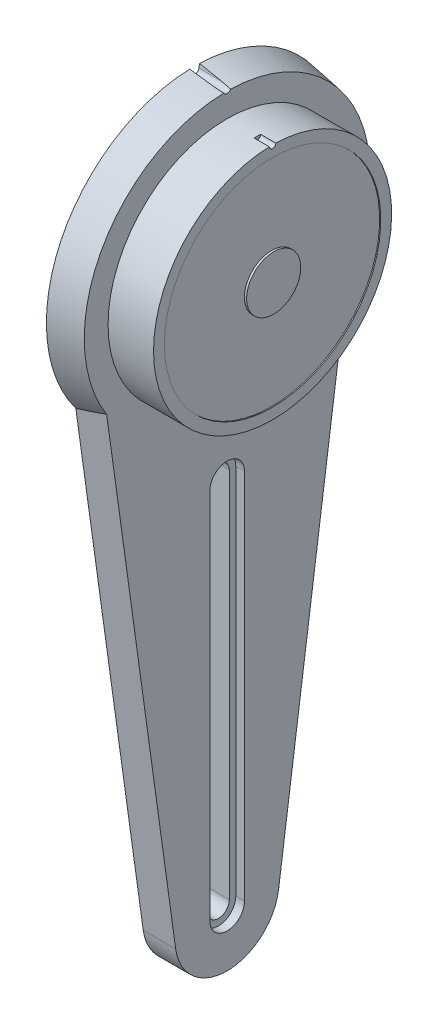
from build123d import *

# Parameters (mm, degrees)
ESQUISSE2_R                        = 0.75
ENL_V_MAT_EXTRU_1_DEPTH            = 3.5
ENL_V_MAT_EXTRU_2_DEPTH            = 50.615395796
EXTRUSION1_DEPTH                   = 7.5
ENL_V_MAT_EXTRU_3_DEPTH            = 3.5
ENL_V_MAT_EXTRU_3_DRAFT            = -7
ENL_V_MAT_EXTRU_3_PROFILE_2_DEPTH  = 3.5
ENL_V_MAT_EXTRU_3_PROFILE_2_DRAFT  = -7
ENL_V_MAT_EXTRU_3_PROFILE_3_DEPTH  = 3.5
ENL_V_MAT_EXTRU_3_PROFILE_3_DRAFT  = -7
ENL_V_MAT_EXTRU_3_PROFILE_4_DEPTH  = 3.5
ENL_V_MAT_EXTRU_3_PROFILE_4_DRAFT  = -7
ENL_V_MAT_EXTRU_3_PROFILE_5_DEPTH  = 3.5
ENL_V_MAT_EXTRU_3_PROFILE_5_DRAFT  = -7
ENL_V_MAT_EXTRU_3_PROFILE_6_DEPTH  = 3.5
ENL_V_MAT_EXTRU_3_PROFILE_6_DRAFT  = -7
ENL_V_MAT_EXTRU_3_PROFILE_7_DEPTH  = 3.5
ENL_V_MAT_EXTRU_3_PROFILE_7_DRAFT  = -7
ENL_V_MAT_EXTRU_3_PROFILE_8_DEPTH  = 3.5
ENL_V_MAT_EXTRU_3_PROFILE_8_DRAFT  = -7
ENL_V_MAT_EXTRU_3_PROFILE_9_DEPTH  = 3.5
ENL_V_MAT_EXTRU_3_PROFILE_9_DRAFT  = -7
ENL_V_MAT_EXTRU_3_PROFILE_10_DEPTH = 3.5
ENL_V_MAT_EXTRU_3_PROFILE_10_DRAFT = -7
ENL_V_MAT_EXTRU_4_DEPTH            = 2


with BuildPart() as part:
    # Esquisse1 → Révolution1 (revolve)
    with BuildSketch(Plane.XY, mode=Mode.PRIVATE) as r_volution1_sk:
        Polygon((0, 0), (0, 34.25), (7.5, 33), (7.5, 27.5), (18, 27.5), (18, 25), (17.75, 25), (17.75, 6.25), (18.25, 6.25), (18.25, 0), align=None)
    revolve(r_volution1_sk.sketch.rotate(Axis((-40.966877637, 0, 0), (1, 0, 0)), 90), axis=Axis((-40.966877637, 0, 0), (1, 0, 0)))

    # Esquisse2 → Enlèv. mat.-Extru.1 (cut)
    with BuildSketch(Plane(origin=(18, 0, 0), x_dir=(0, 0, -1), z_dir=(1, 0, 0))):
        with Locations((0, 27.5)):
            Circle(ESQUISSE2_R)
    extrude(amount=-ENL_V_MAT_EXTRU_1_DEPTH, mode=Mode.SUBTRACT)

    # Esquisse3 → Enlèv. mat.-Extru.2 (cut, through all)
    with BuildSketch(Plane(origin=(7.5, 0, 0), x_dir=(0, 0, -1), z_dir=(1, 0, 0))):
        with BuildLine():
            Line((-0.983364169, 33.368354985), (-1.997654411, 38.859376491))
            Line((-1.997654411, 38.859376491), (1.964936251, 38.859376491))
            Line((1.964936251, 38.859376491), (0.984396051, 33.374032918))
            ThreePointArc((0.984396051, 33.374032918), (0.002885468, 32.550004163), (-0.983364169, 33.368354985))
        make_face()
    extrude(amount=-ENL_V_MAT_EXTRU_2_DEPTH, mode=Mode.SUBTRACT)

    # Esquisse4 → Extrusion1 (add)
    with BuildSketch(Plane.ZY):
        with BuildLine():
            Line((29.715450244, -4.122137405), (11.886180098, -132.648854962))
            ThreePointArc((11.886180098, -132.648854962), (0, -143), (-11.886180098, -132.648854962))
            Line((-11.886180098, -132.648854962), (-29.715450244, -4.122137405))
            ThreePointArc((-29.715450244, -4.122137405), (0, 30), (29.715450244, -4.122137405))
        make_face()
        with BuildLine():
            Line((2.5, -45), (2.5, -131))
            ThreePointArc((2.5, -131), (0, -133.5), (-2.5, -131))
            Line((-2.5, -131), (-2.5, -45))
            ThreePointArc((-2.5, -45), (0, -42.5), (2.5, -45))
        make_face(mode=Mode.SUBTRACT)
    extrude(amount=-EXTRUSION1_DEPTH)


with BuildPart() as enl_v_mat_extru_3_tool:
    # Esquisse5 → Enlèv. mat.-Extru.3 (with draft: the straight prism first)
    with BuildSketch(Plane.ZY):
        Polygon((-11.039827175, -106), (-6, -106), (-6, -88), (-13.536793321, -88), align=None)
    extrude(amount=-ENL_V_MAT_EXTRU_3_DEPTH)
    # Enlèv. mat.-Extru.3: the draft: its side faces are tilted about the plane it starts from
    enl_v_mat_extru_3_sides = [enl_v_mat_extru_3_tool.faces().sort_by_distance(p)[0] for p in [
        (1.75, -106, -8.519913587),
        (1.75, -97, -6),
        (1.75, -88, -9.768396661),
        (1.75, -97, -12.288310248),
    ]]
    draft(enl_v_mat_extru_3_sides, Plane.ZY, ENL_V_MAT_EXTRU_3_DRAFT)


with BuildPart() as part_1:
    add(part.part)

    # Enlèv. mat.-Extru.3: cut by enl_v_mat_extru_3_tool
    add(enl_v_mat_extru_3_tool.part, mode=Mode.SUBTRACT)


with BuildPart() as enl_v_mat_extru_3_profile_2_tool:
    # Esquisse5 → Enlèv. mat.-Extru.3 profile 2 (with draft: the straight prism first)
    with BuildSketch(Plane.ZY):
        with BuildLine():
            ThreePointArc((-6, -45), (-4.582575695, -41.127016654), (-1, -39.083920217))
            Line((-1, -39.083920217), (-1, -34.235398347))
            ThreePointArc((-1, -34.235398347), (-6.197147295, -33.684682949), (-11.25, -32.349652239))
            Line((-11.25, -32.349652239), (-11.25, -65))
            Line((-11.25, -65), (-6, -65))
            Line((-6, -65), (-6, -45))
        make_face()
    extrude(amount=-ENL_V_MAT_EXTRU_3_PROFILE_2_DEPTH)
    # Enlèv. mat.-Extru.3 profile 2: the draft: its side faces are tilted about the plane it starts from
    enl_v_mat_extru_3_profile_2_sides = [enl_v_mat_extru_3_profile_2_tool.faces().sort_by_distance(p)[0] for p in [
        (1.75, -41.127016654, -4.582575695),
        (1.75, -36.659659282, -1),
        (1.75, -33.684682949, -6.197147295),
        (1.75, -48.67482612, -11.25),
        (1.75, -65, -8.625),
        (1.75, -55, -6),
    ]]
    draft(enl_v_mat_extru_3_profile_2_sides, Plane.ZY, ENL_V_MAT_EXTRU_3_PROFILE_2_DRAFT)


with BuildPart() as part_2:
    add(part_1.part)

    # Enlèv. mat.-Extru.3 profile 2: cut by enl_v_mat_extru_3_profile_2_tool
    add(enl_v_mat_extru_3_profile_2_tool.part, mode=Mode.SUBTRACT)


with BuildPart() as enl_v_mat_extru_3_profile_3_tool:
    # Esquisse5 → Enlèv. mat.-Extru.3 profile 3 (with draft: the straight prism first)
    with BuildSketch(Plane.ZY):
        with BuildLine():
            Line((-22.116364137, -26.152035052), (-16.727361175, -65))
            Line((-16.727361175, -65), (-13.25, -65))
            Line((-13.25, -65), (-13.25, -31.583223395))
            ThreePointArc((-13.25, -31.583223395), (-17.890482939, -29.206045953), (-22.116364137, -26.152035052))
        make_face()
    extrude(amount=-ENL_V_MAT_EXTRU_3_PROFILE_3_DEPTH)
    # Enlèv. mat.-Extru.3 profile 3: the draft: its side faces are tilted about the plane it starts from
    enl_v_mat_extru_3_profile_3_sides = [enl_v_mat_extru_3_profile_3_tool.faces().sort_by_distance(p)[0] for p in [
        (1.75, -45.576017526, -19.421862656),
        (1.75, -65, -14.988680587),
        (1.75, -48.291611697, -13.25),
        (1.75, -29.206045953, -17.890482939),
    ]]
    draft(enl_v_mat_extru_3_profile_3_sides, Plane.ZY, ENL_V_MAT_EXTRU_3_PROFILE_3_DRAFT)


with BuildPart() as part_3:
    add(part_2.part)

    # Enlèv. mat.-Extru.3 profile 3: cut by enl_v_mat_extru_3_profile_3_tool
    add(enl_v_mat_extru_3_profile_3_tool.part, mode=Mode.SUBTRACT)


with BuildPart() as enl_v_mat_extru_3_profile_4_tool:
    # Esquisse5 → Enlèv. mat.-Extru.3 profile 4 (with draft: the straight prism first)
    with BuildSketch(Plane.ZY):
        with BuildLine():
            Line((-1, -138.433034374), (-1, -136.916079783))
            ThreePointArc((-1, -136.916079783), (-4.582575695, -134.872983346), (-6, -131))
            Line((-6, -131), (-6, -108))
            Line((-6, -108), (-10.762386492, -108))
            Line((-10.762386492, -108), (-7.428862561, -132.030534351))
            ThreePointArc((-7.428862561, -132.030534351), (-5.292393849, -136.314185483), (-1, -138.433034374))
        make_face()
    extrude(amount=-ENL_V_MAT_EXTRU_3_PROFILE_4_DEPTH)
    # Enlèv. mat.-Extru.3 profile 4: the draft: its side faces are tilted about the plane it starts from
    enl_v_mat_extru_3_profile_4_sides = [enl_v_mat_extru_3_profile_4_tool.faces().sort_by_distance(p)[0] for p in [
        (1.75, -137.674557078, -1),
        (1.75, -134.872983346, -4.582575695),
        (1.75, -119.5, -6),
        (1.75, -108, -8.381193246),
        (1.75, -120.015267176, -9.095624526),
        (1.75, -136.314185483, -5.292393849),
    ]]
    draft(enl_v_mat_extru_3_profile_4_sides, Plane.ZY, ENL_V_MAT_EXTRU_3_PROFILE_4_DRAFT)


with BuildPart() as part_4:
    add(part_3.part)

    # Enlèv. mat.-Extru.3 profile 4: cut by enl_v_mat_extru_3_profile_4_tool
    add(enl_v_mat_extru_3_profile_4_tool.part, mode=Mode.SUBTRACT)


with BuildPart() as enl_v_mat_extru_3_profile_5_tool:
    # Esquisse5 → Enlèv. mat.-Extru.3 profile 5 (with draft: the straight prism first)
    with BuildSketch(Plane.ZY):
        Polygon((-13.814234004, -86), (-6, -86), (-6, -67), (-16.449920492, -67), align=None)
    extrude(amount=-ENL_V_MAT_EXTRU_3_PROFILE_5_DEPTH)
    # Enlèv. mat.-Extru.3 profile 5: the draft: its side faces are tilted about the plane it starts from
    enl_v_mat_extru_3_profile_5_sides = [enl_v_mat_extru_3_profile_5_tool.faces().sort_by_distance(p)[0] for p in [
        (1.75, -86, -9.907117002),
        (1.75, -76.5, -6),
        (1.75, -67, -11.224960246),
        (1.75, -76.5, -15.132077248),
    ]]
    draft(enl_v_mat_extru_3_profile_5_sides, Plane.ZY, ENL_V_MAT_EXTRU_3_PROFILE_5_DRAFT)


with BuildPart() as part_5:
    add(part_4.part)

    # Enlèv. mat.-Extru.3 profile 5: cut by enl_v_mat_extru_3_profile_5_tool
    add(enl_v_mat_extru_3_profile_5_tool.part, mode=Mode.SUBTRACT)


with BuildPart() as enl_v_mat_extru_3_profile_6_tool:
    # Esquisse5 → Enlèv. mat.-Extru.3 profile 6 (with draft: the straight prism first)
    with BuildSketch(Plane.ZY):
        with BuildLine():
            Line((10.762386492, -108), (6, -108))
            Line((6, -108), (6, -131))
            ThreePointArc((6, -131), (4.582575695, -134.872983346), (1, -136.916079783))
            Line((1, -136.916079783), (1, -138.433034374))
            ThreePointArc((1, -138.433034374), (5.292393849, -136.314185483), (7.428862561, -132.030534351))
            Line((7.428862561, -132.030534351), (10.762386492, -108))
        make_face()
    extrude(amount=-ENL_V_MAT_EXTRU_3_PROFILE_6_DEPTH)
    # Enlèv. mat.-Extru.3 profile 6: the draft: its side faces are tilted about the plane it starts from
    enl_v_mat_extru_3_profile_6_sides = [enl_v_mat_extru_3_profile_6_tool.faces().sort_by_distance(p)[0] for p in [
        (1.75, -120.015267176, 9.095624526),
        (1.75, -108, 8.381193246),
        (1.75, -119.5, 6),
        (1.75, -134.872983346, 4.582575695),
        (1.75, -137.674557078, 1),
        (1.75, -136.314185483, 5.292393849),
    ]]
    draft(enl_v_mat_extru_3_profile_6_sides, Plane.ZY, ENL_V_MAT_EXTRU_3_PROFILE_6_DRAFT)


with BuildPart() as part_6:
    add(part_5.part)

    # Enlèv. mat.-Extru.3 profile 6: cut by enl_v_mat_extru_3_profile_6_tool
    add(enl_v_mat_extru_3_profile_6_tool.part, mode=Mode.SUBTRACT)


with BuildPart() as enl_v_mat_extru_3_profile_7_tool:
    # Esquisse5 → Enlèv. mat.-Extru.3 profile 7 (with draft: the straight prism first)
    with BuildSketch(Plane.ZY):
        Polygon((13.536793321, -88), (6, -88), (6, -106), (11.039827175, -106), align=None)
    extrude(amount=-ENL_V_MAT_EXTRU_3_PROFILE_7_DEPTH)
    # Enlèv. mat.-Extru.3 profile 7: the draft: its side faces are tilted about the plane it starts from
    enl_v_mat_extru_3_profile_7_sides = [enl_v_mat_extru_3_profile_7_tool.faces().sort_by_distance(p)[0] for p in [
        (1.75, -88, 9.768396661),
        (1.75, -97, 6),
        (1.75, -106, 8.519913587),
        (1.75, -97, 12.288310248),
    ]]
    draft(enl_v_mat_extru_3_profile_7_sides, Plane.ZY, ENL_V_MAT_EXTRU_3_PROFILE_7_DRAFT)


with BuildPart() as part_7:
    add(part_6.part)

    # Enlèv. mat.-Extru.3 profile 7: cut by enl_v_mat_extru_3_profile_7_tool
    add(enl_v_mat_extru_3_profile_7_tool.part, mode=Mode.SUBTRACT)


with BuildPart() as enl_v_mat_extru_3_profile_8_tool:
    # Esquisse5 → Enlèv. mat.-Extru.3 profile 8 (with draft: the straight prism first)
    with BuildSketch(Plane.ZY):
        with BuildLine():
            Line((11.25, -65), (11.25, -32.349652239))
            ThreePointArc((11.25, -32.349652239), (6.197147295, -33.684682949), (1, -34.235398347))
            Line((1, -34.235398347), (1, -39.083920217))
            ThreePointArc((1, -39.083920217), (4.582575695, -41.127016654), (6, -45))
            Line((6, -45), (6, -65))
            Line((6, -65), (11.25, -65))
        make_face()
    extrude(amount=-ENL_V_MAT_EXTRU_3_PROFILE_8_DEPTH)
    # Enlèv. mat.-Extru.3 profile 8: the draft: its side faces are tilted about the plane it starts from
    enl_v_mat_extru_3_profile_8_sides = [enl_v_mat_extru_3_profile_8_tool.faces().sort_by_distance(p)[0] for p in [
        (1.75, -55, 6),
        (1.75, -65, 8.625),
        (1.75, -48.67482612, 11.25),
        (1.75, -33.684682949, 6.197147295),
        (1.75, -36.659659282, 1),
        (1.75, -41.127016654, 4.582575695),
    ]]
    draft(enl_v_mat_extru_3_profile_8_sides, Plane.ZY, ENL_V_MAT_EXTRU_3_PROFILE_8_DRAFT)


with BuildPart() as part_8:
    add(part_7.part)

    # Enlèv. mat.-Extru.3 profile 8: cut by enl_v_mat_extru_3_profile_8_tool
    add(enl_v_mat_extru_3_profile_8_tool.part, mode=Mode.SUBTRACT)


with BuildPart() as enl_v_mat_extru_3_profile_9_tool:
    # Esquisse5 → Enlèv. mat.-Extru.3 profile 9 (with draft: the straight prism first)
    with BuildSketch(Plane.ZY):
        Polygon((6, -67), (6, -86), (13.814234004, -86), (16.449920492, -67), align=None)
    extrude(amount=-ENL_V_MAT_EXTRU_3_PROFILE_9_DEPTH)
    # Enlèv. mat.-Extru.3 profile 9: the draft: its side faces are tilted about the plane it starts from
    enl_v_mat_extru_3_profile_9_sides = [enl_v_mat_extru_3_profile_9_tool.faces().sort_by_distance(p)[0] for p in [
        (1.75, -76.5, 6),
        (1.75, -86, 9.907117002),
        (1.75, -76.5, 15.132077248),
        (1.75, -67, 11.224960246),
    ]]
    draft(enl_v_mat_extru_3_profile_9_sides, Plane.ZY, ENL_V_MAT_EXTRU_3_PROFILE_9_DRAFT)


with BuildPart() as part_9:
    add(part_8.part)

    # Enlèv. mat.-Extru.3 profile 9: cut by enl_v_mat_extru_3_profile_9_tool
    add(enl_v_mat_extru_3_profile_9_tool.part, mode=Mode.SUBTRACT)


with BuildPart() as enl_v_mat_extru_3_profile_10_tool:
    # Esquisse5 → Enlèv. mat.-Extru.3 profile 10 (with draft: the straight prism first)
    with BuildSketch(Plane.ZY):
        with BuildLine():
            Line((13.25, -65), (16.727361175, -65))
            Line((16.727361175, -65), (22.116364137, -26.152035052))
            ThreePointArc((22.116364137, -26.152035052), (17.890482939, -29.206045953), (13.25, -31.583223395))
            Line((13.25, -31.583223395), (13.25, -65))
        make_face()
    extrude(amount=-ENL_V_MAT_EXTRU_3_PROFILE_10_DEPTH)
    # Enlèv. mat.-Extru.3 profile 10: the draft: its side faces are tilted about the plane it starts from
    enl_v_mat_extru_3_profile_10_sides = [enl_v_mat_extru_3_profile_10_tool.faces().sort_by_distance(p)[0] for p in [
        (1.75, -48.291611697, 13.25),
        (1.75, -65, 14.988680587),
        (1.75, -45.576017526, 19.421862656),
        (1.75, -29.206045953, 17.890482939),
    ]]
    draft(enl_v_mat_extru_3_profile_10_sides, Plane.ZY, ENL_V_MAT_EXTRU_3_PROFILE_10_DRAFT)


with BuildPart() as part_10:
    add(part_9.part)

    # Enlèv. mat.-Extru.3 profile 10: cut by enl_v_mat_extru_3_profile_10_tool
    add(enl_v_mat_extru_3_profile_10_tool.part, mode=Mode.SUBTRACT)

    # Esquisse6 → Enlèv. mat.-Extru.4 (cut)
    with BuildSketch(Plane(origin=(7.5, 0, 0), x_dir=(0, 0, -1), z_dir=(1, 0, 0))):
        with BuildLine():
            Line((4, -45), (4, -131))
            ThreePointArc((4, -131), (0, -135), (-4, -131))
            Line((-4, -131), (-4, -45))
            ThreePointArc((-4, -45), (0, -41), (4, -45))
        make_face()
    extrude(amount=-ENL_V_MAT_EXTRU_4_DEPTH, mode=Mode.SUBTRACT)


solid = part_10.part
